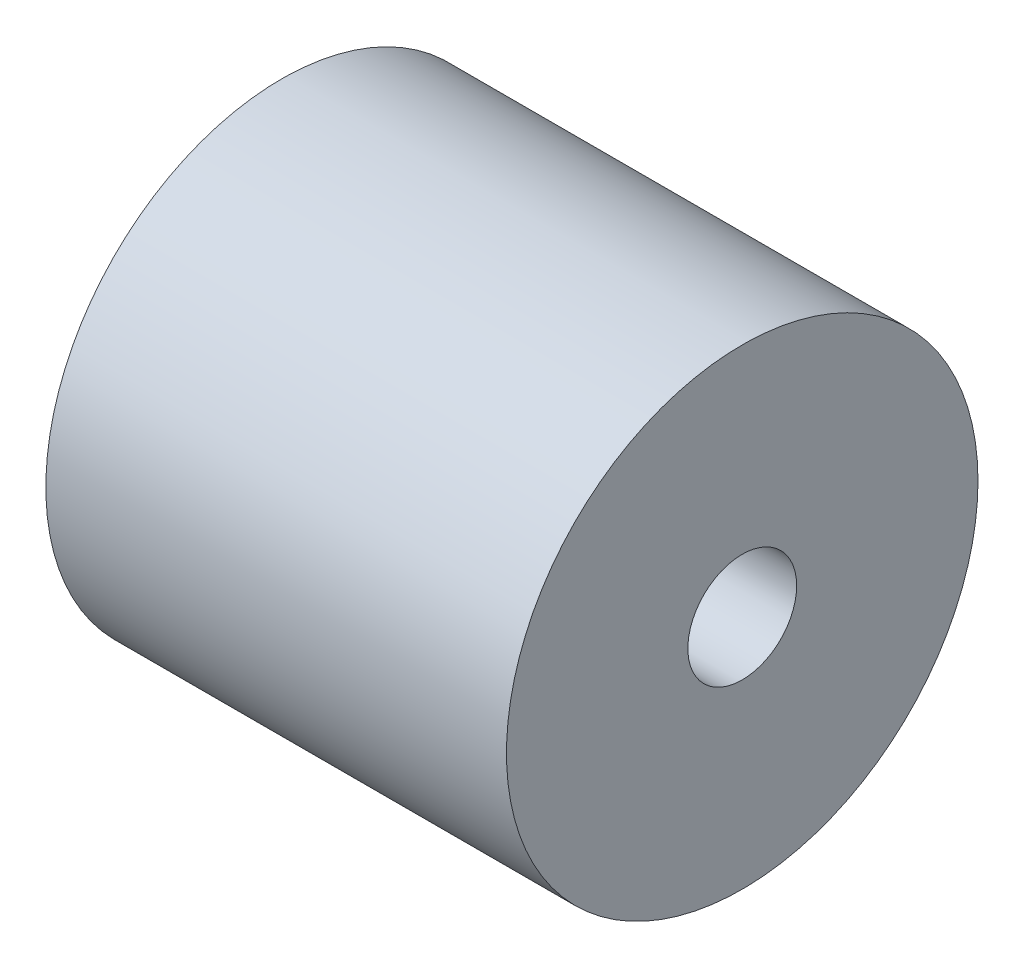
from build123d import *

# Parameters (mm, degrees)
SKETCH1_R           = 6.5
SKETCH1_R_2         = 1.5
BOSS_EXTRUDE1_DEPTH = 12.7


with BuildPart() as part:
    # Sketch1 → Boss-Extrude1 (new body)
    with BuildSketch(Plane(origin=(0, 0, 0), x_dir=(0, 0, -1), z_dir=(1, 0, 0))):
        Circle(SKETCH1_R)
        Circle(SKETCH1_R_2, mode=Mode.SUBTRACT)
    extrude(amount=BOSS_EXTRUDE1_DEPTH)


solid = part.part
